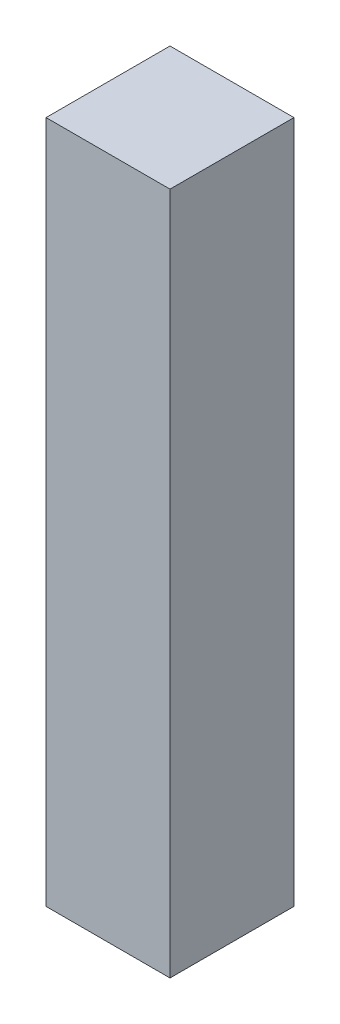
from build123d import *

# Parameters (mm, degrees)
SKETCH1_W           = 2.54
SKETCH1_H           = 2.54
BOSS_EXTRUDE1_DEPTH = 14


with BuildPart() as part:
    # Sketch1 → Boss-Extrude1 (new body)
    with BuildSketch(Plane(origin=(0, 0, 0), x_dir=(1, 0, 0), z_dir=(0, 1, 0))):
        Rectangle(SKETCH1_W, SKETCH1_H)
    extrude(amount=BOSS_EXTRUDE1_DEPTH)


solid = part.part
